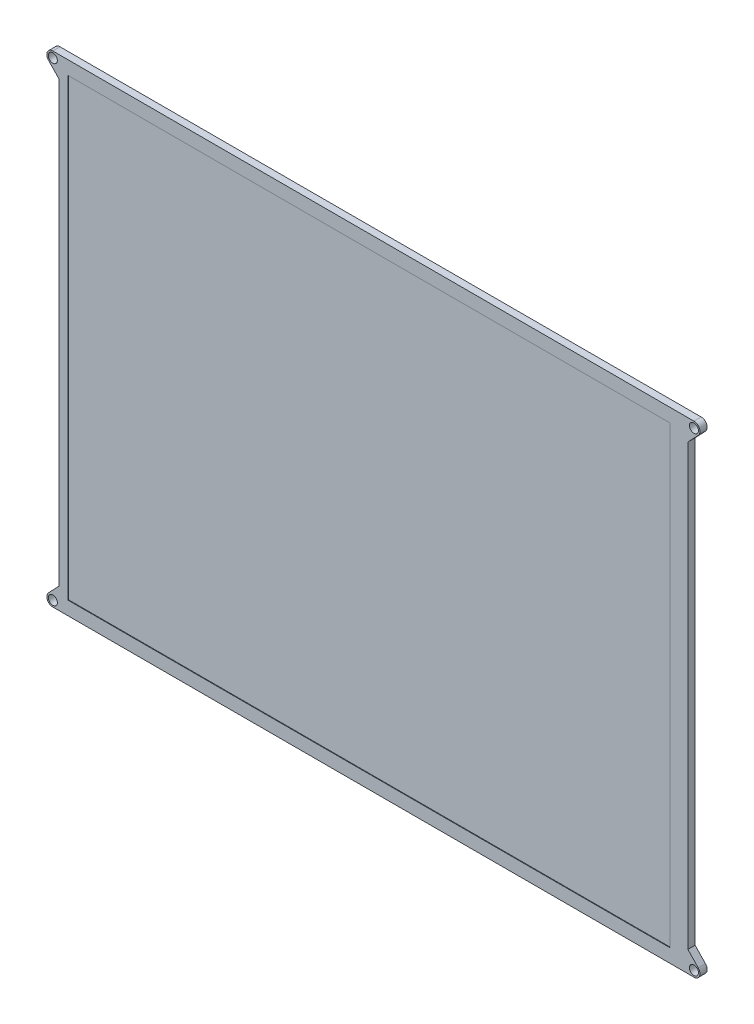
from build123d import *

# Parameters (mm, degrees)
CROQUIS1_W              = 209
CROQUIS1_H              = 160
CROQUIS1_R              = 1.5
SALIENTE_EXTRUIR1_DEPTH = 2.4
CROQUIS2_W              = 200
CROQUIS2_H              = 151
CORTAR_EXTRUIR1_DEPTH   = 0.2


with BuildPart() as part:
    # Croquis1 → Saliente-Extruir1 (new body)
    with BuildSketch(Plane.XY):
        Rectangle(CROQUIS1_W, CROQUIS1_H)
        with BuildLine():
            Line((-104.5, 73), (-104.5, 80))
            Line((-104.5, 80), (-106.5, 80))
            ThreePointArc((-106.5, 80), (-108.33829006, 78.787838597), (-107.948275862, 76.620689655))
            Line((-107.948275862, 76.620689655), (-104.5, 73))
        make_face()
        with Locations((-106.5, 78)):
            Circle(CROQUIS1_R, mode=Mode.SUBTRACT)
        with BuildLine():
            Line((106.5, 80), (104.5, 80))
            Line((104.5, 80), (104.5, 73))
            Line((104.5, 73), (107.948275862, 76.620689655))
            ThreePointArc((107.948275862, 76.620689655), (108.33829006, 78.787838597), (106.5, 80))
        make_face()
        with Locations((106.5, 78)):
            Circle(CROQUIS1_R, mode=Mode.SUBTRACT)
        with BuildLine():
            Line((107.948275862, -76.620689655), (104.5, -73))
            Line((104.5, -73), (104.5, -80))
            Line((104.5, -80), (106.5, -80))
            ThreePointArc((106.5, -80), (108.33829006, -78.787838597), (107.948275862, -76.620689655))
        make_face()
        with Locations((106.5, -78)):
            Circle(CROQUIS1_R, mode=Mode.SUBTRACT)
        with BuildLine():
            Line((-104.5, -80), (-104.5, -73))
            Line((-104.5, -73), (-107.948275862, -76.620689655))
            ThreePointArc((-107.948275862, -76.620689655), (-108.33829006, -78.787838597), (-106.5, -80))
            Line((-106.5, -80), (-104.5, -80))
        make_face()
        with Locations((-106.5, -78)):
            Circle(CROQUIS1_R, mode=Mode.SUBTRACT)
    extrude(amount=SALIENTE_EXTRUIR1_DEPTH)

    # Croquis2 → Cortar-Extruir1 (cut)
    with BuildSketch(Plane.XY.offset(2.4)):
        with Locations((-1.5, 0)):
            Rectangle(CROQUIS2_W, CROQUIS2_H)
    extrude(amount=-CORTAR_EXTRUIR1_DEPTH, mode=Mode.SUBTRACT)


solid = part.part
